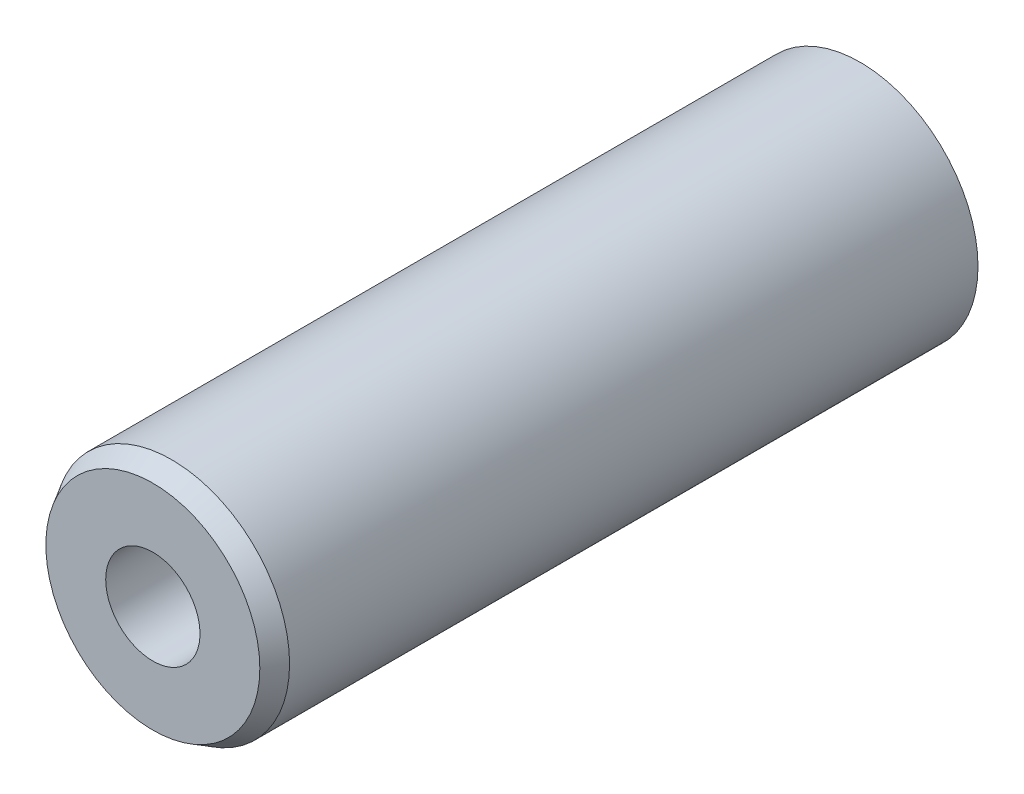
from build123d import *

# Parameters (mm, degrees)
SKETCH1_R                       = 2.5
BOSS_EXTRUDE1_DEPTH             = 15
SKETCH2_R                       = 1
CUT_EXTRUDE1_DEPTH              = 16
TAP_DRILL_FOR_M3X0_5_TAP1_D     = 2.5
TAP_DRILL_FOR_M3X0_5_TAP1_DEPTH = 11
TAP_DRILL_FOR_M3X0_5_TAP1_TIP   = 0.751075774
CHAMFER1_SIZE                   = 0.4
CHAMFER1_SIZE2                  = 0.230940108
CHAMFER2_SIZE                   = 0.4
CHAMFER2_SIZE2                  = 0.692820323


with BuildPart() as part:
    # Sketch1 → Boss-Extrude1 (new body)
    with BuildSketch(Plane.XY):
        Circle(SKETCH1_R)
    extrude(amount=BOSS_EXTRUDE1_DEPTH)

    # Sketch2 → Cut-Extrude1 (cut, through all)
    with BuildSketch(Plane(origin=(0, 0, 0), x_dir=(-1, 0, 0), z_dir=(0, 0, -1))):
        Circle(SKETCH2_R)
    extrude(amount=-CUT_EXTRUDE1_DEPTH, mode=Mode.SUBTRACT)

    # Tap Drill for M3x0.5 Tap1
    with Locations(Plane(origin=(0, 0, 0), x_dir=(-1, 0, 0), z_dir=(0, 0, -1))):
        with Locations((0, 0)):
            Hole(TAP_DRILL_FOR_M3X0_5_TAP1_D / 2, depth=TAP_DRILL_FOR_M3X0_5_TAP1_DEPTH)
            with Locations((0, 0, -(TAP_DRILL_FOR_M3X0_5_TAP1_DEPTH + TAP_DRILL_FOR_M3X0_5_TAP1_TIP / 2))):  # 118° drill point
                Cone(0, TAP_DRILL_FOR_M3X0_5_TAP1_D / 2, TAP_DRILL_FOR_M3X0_5_TAP1_TIP, mode=Mode.SUBTRACT)

    # Chamfer1
    chamfer1_edges = [part.edges().sort_by_distance(p)[0] for p in [
        (-2.5, 0, 15),
    ]]
    chamfer1_side = [part.faces().sort_by_distance(p)[0] for p in [
        (-2.5, 0, 7.5),
    ]]
    chamfer(chamfer1_edges, length=CHAMFER1_SIZE, length2=CHAMFER1_SIZE2, reference=chamfer1_side[0])

    # Chamfer2
    chamfer2_edges = [part.edges().sort_by_distance(p)[0] for p in [
        (-1.25, 0, 0),
    ]]
    chamfer2_side = [part.faces().sort_by_distance(p)[0] for p in [
        (-2.429289322, 0, 0),
    ]]
    chamfer(chamfer2_edges, length=CHAMFER2_SIZE, length2=CHAMFER2_SIZE2, reference=chamfer2_side[0])


solid = part.part
